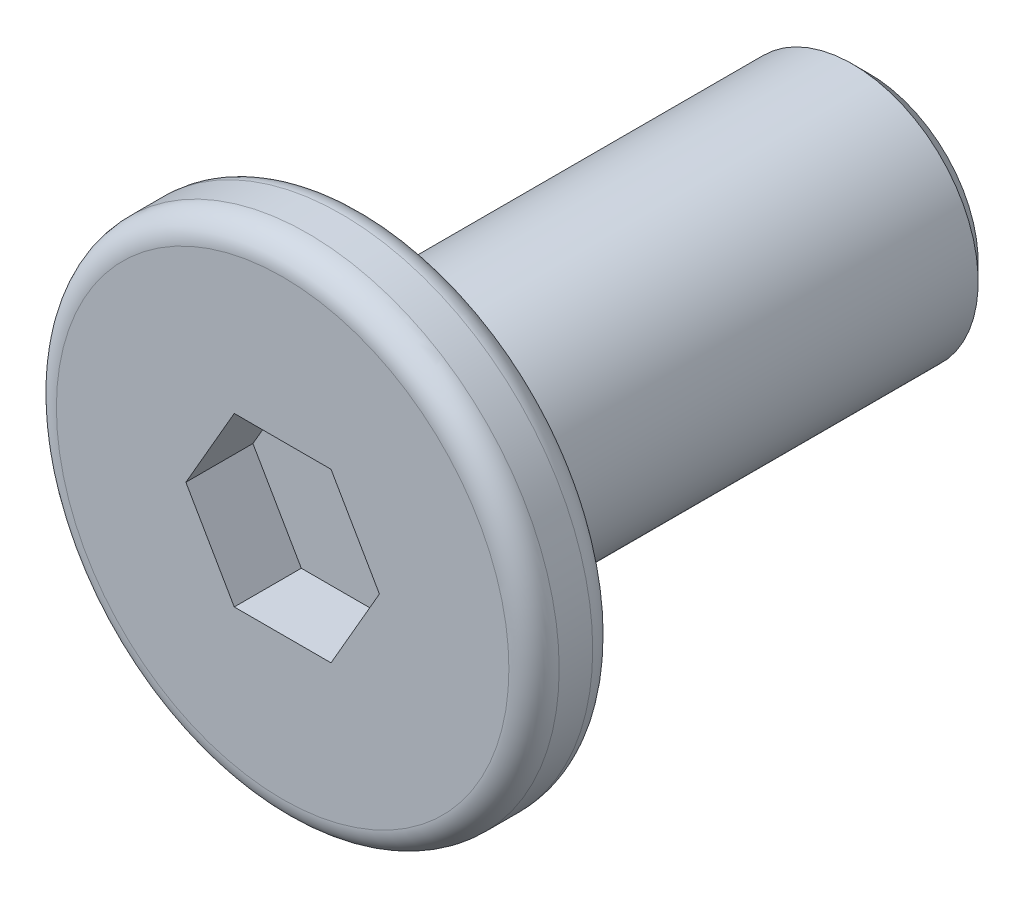
from build123d import *

# Parameters (mm, degrees)
SKETCH_1_R          = 3
EXTRUDE_1_DEPTH     = 0.5
SKETCH_2_R          = 1.5
EXTRUDE_2_DEPTH     = 6
CHAMFER_1_SIZE      = 0.2
CUT_EXTRUDE_1_DEPTH = 0.8
FILLET_2_R          = 0.3


with BuildPart() as part:
    # 草图1 → 凸台-拉伸1 (new body, symmetric)
    with BuildSketch(Plane.XY):
        Circle(SKETCH_1_R)
    extrude(amount=EXTRUDE_1_DEPTH, both=True)

    # 草图2 → 凸台-拉伸2 (add)
    with BuildSketch(Plane(origin=(0, 0, -0.5), x_dir=(-1, 0, 0), z_dir=(0, 0, -1))):
        Circle(SKETCH_2_R)
    extrude(amount=EXTRUDE_2_DEPTH)

    # 倒角1
    chamfer_1_edges = [part.edges().sort_by_distance(p)[0] for p in [
        (1.5, 0, -6.5),
    ]]
    chamfer(chamfer_1_edges, length=CHAMFER_1_SIZE)

    # 草图3 → 切除-拉伸1 (cut)
    with BuildSketch(Plane.XY.offset(0.5)):
        Polygon((1.154700538, 0), (0.577350269, 1), (-0.577350269, 1), (-1.154700538, 0), (-0.577350269, -1), (0.577350269, -1), align=None)
    extrude(amount=-CUT_EXTRUDE_1_DEPTH, mode=Mode.SUBTRACT)

    # 圆角2
    fillet_2_edges = [part.edges().sort_by_distance(p)[0] for p in [
        (-3, 0, -0.5),
        (-3, 0, 0.5),
    ]]
    fillet(fillet_2_edges, radius=FILLET_2_R)


solid = part.part
